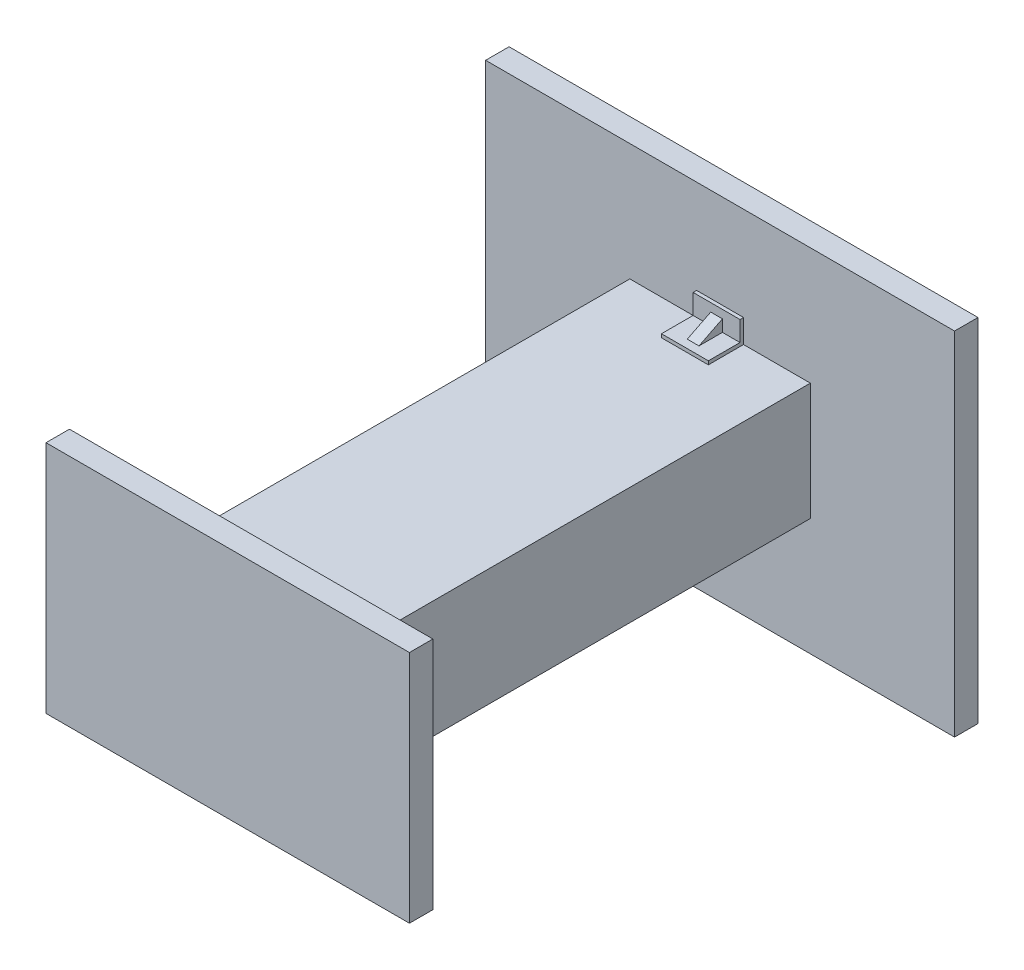
from build123d import *

# Parameters (mm, degrees)
SKETCH1_W            = 155
SKETCH1_H            = 100
BOSS_EXTRUDE1_DEPTH  = 10
SKETCH5_W            = 77
SKETCH5_H            = 50
BOSS_EXTRUDE5_DEPTH  = 200
SKETCH6_W            = 200
SKETCH6_H            = 150
BOSS_EXTRUDE12_DEPTH = 10
BOSS_EXTRUDE13_DEPTH = 10
BOSS_EXTRUDE14_DEPTH = 2.5
MIRROR2_COPY_1_DEPTH = 10
MIRROR2_COPY_2_DEPTH = 2.5
SCALE3_SCALE         = 2


with BuildPart() as part:
    # Sketch1 → Boss-Extrude1 (new body)
    with BuildSketch(Plane.XY):
        Rectangle(SKETCH1_W, SKETCH1_H)
    extrude(amount=BOSS_EXTRUDE1_DEPTH)

    # Sketch5 → Boss-Extrude5 (add)
    with BuildSketch(Plane(origin=(0, 0, 0), x_dir=(-1, 0, 0), z_dir=(0, 0, -1))):
        Rectangle(SKETCH5_W, SKETCH5_H)
    extrude(amount=BOSS_EXTRUDE5_DEPTH)

    # Sketch6 → Boss-Extrude12 (add)
    with BuildSketch(Plane(origin=(0, 0, -200), x_dir=(-1, 0, 0), z_dir=(0, 0, -1))):
        Rectangle(SKETCH6_W, SKETCH6_H)
    extrude(amount=BOSS_EXTRUDE12_DEPTH)

    # Sketch7 → Boss-Extrude13 (add, symmetric)
    with BuildSketch(Plane(origin=(0, 0, 0), x_dir=(0, 0, -1), z_dir=(1, 0, 0))):
        Polygon((15, -26.5), (15, -25), (0, -25), (0, -35), (1.5, -35), (1.5, -31.5), (1.5, -26.5), (11.5, -26.5), align=None)
    boss_extrude13 = extrude(amount=BOSS_EXTRUDE13_DEPTH, both=True)

    # Sketch7_3 → Boss-Extrude14 (add, symmetric)
    with BuildSketch(Plane(origin=(0, 0, 0), x_dir=(0, 0, -1), z_dir=(1, 0, 0))):
        Polygon((1.5, -31.5), (11.5, -26.5), (1.5, -26.5), align=None)
    boss_extrude14 = extrude(amount=BOSS_EXTRUDE14_DEPTH, both=True)

    # Mirror1: Boss-Extrude13, Boss-Extrude14 across plane
    add(boss_extrude13.mirror(Plane.ZX))
    add(boss_extrude14.mirror(Plane.ZX))

    # Mirror2: Boss-Extrude13, Boss-Extrude14 across plane
    add(boss_extrude13.mirror(Plane(origin=(0, 0, -100), x_dir=(1, 0, 0), z_dir=(0, 0, -1))))
    add(boss_extrude14.mirror(Plane(origin=(0, 0, -100), x_dir=(1, 0, 0), z_dir=(0, 0, -1))))

    # Mirror2 copy 1 sketch → Mirror2 copy 1 (add, symmetric)
    with BuildSketch(Plane(origin=(0, 0, -200), x_dir=(0, 0, 1), z_dir=(1, 0, 0))):
        Polygon((15, -26.5), (15, -25), (0, -25), (0, -35), (1.5, -35), (1.5, -31.5), (1.5, -26.5), (11.5, -26.5), align=None)
    extrude(amount=MIRROR2_COPY_1_DEPTH, both=True)

    # Mirror2 copy 2 sketch → Mirror2 copy 2 (add, symmetric)
    with BuildSketch(Plane(origin=(0, 0, -200), x_dir=(0, 0, 1), z_dir=(1, 0, 0))):
        Polygon((1.5, -31.5), (11.5, -26.5), (1.5, -26.5), align=None)
    extrude(amount=MIRROR2_COPY_2_DEPTH, both=True)


with BuildPart() as part_1:
    # Scale3: scaled about (0, 0, -112.394978507)
    add(part.part.scale(SCALE3_SCALE).moved(Location((0, 0, 112.394978507))))


solid = part_1.part
